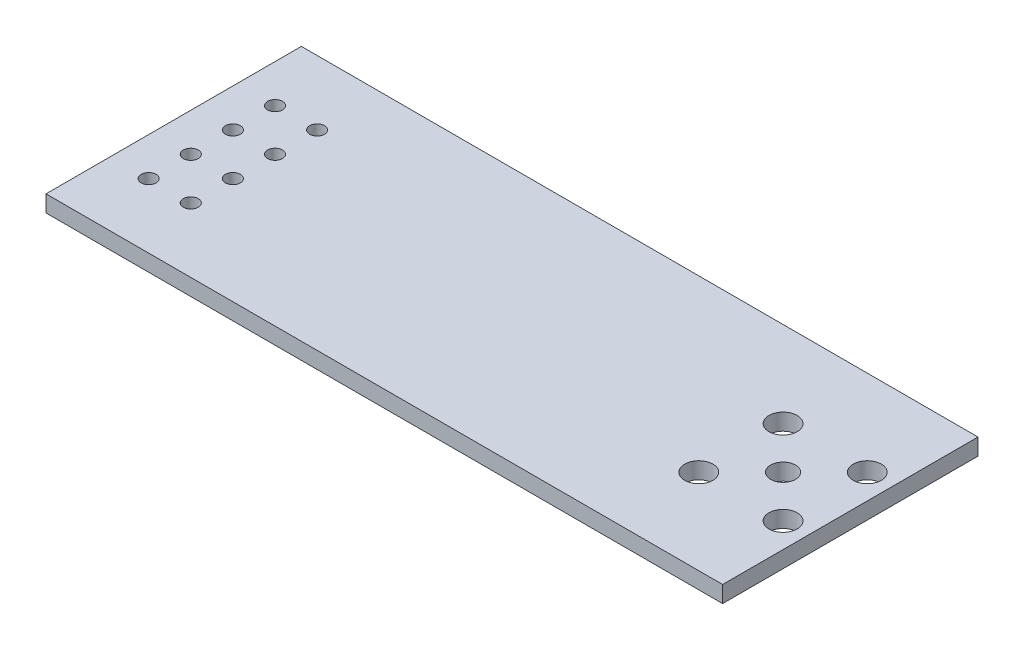
from build123d import *

# Parameters (mm, degrees)
SKETCH_1_W      = 40.8
SKETCH_1_H      = 15.4
SKETCH_1_R      = 0.45
SKETCH_1_R_2    = 0.85
SKETCH_1_R_3    = 0.75
EXTRUDE_1_DEPTH = 1


with BuildPart() as part:
    # Эскиз1 → Бобышка-Вытянуть1 (new body)
    with BuildSketch(Plane(origin=(0, 0, 0), x_dir=(1, 0, 0), z_dir=(0, 1, 0))):
        with Locations((20.4, 7.7)):
            Rectangle(SKETCH_1_W, SKETCH_1_H)
        with Locations((2.299992341, 3.89)):
            Circle(SKETCH_1_R, mode=Mode.SUBTRACT)
        with Locations((2.299993928, 6.43)):
            Circle(SKETCH_1_R, mode=Mode.SUBTRACT)
        with Locations((2.299995515, 8.97)):
            Circle(SKETCH_1_R, mode=Mode.SUBTRACT)
        with Locations((2.3, 11.51)):
            Circle(SKETCH_1_R, mode=Mode.SUBTRACT)
        with Locations((4.839992341, 3.89)):
            Circle(SKETCH_1_R, mode=Mode.SUBTRACT)
        with Locations((4.839992341, 6.43)):
            Circle(SKETCH_1_R, mode=Mode.SUBTRACT)
        with Locations((4.839992341, 8.97)):
            Circle(SKETCH_1_R, mode=Mode.SUBTRACT)
        with Locations((4.839992341, 11.51)):
            Circle(SKETCH_1_R, mode=Mode.SUBTRACT)
        with Locations((34.22, 5.144366898)):
            Circle(SKETCH_1_R_2, mode=Mode.SUBTRACT)
        with Locations((34.22, 10.224366898)):
            Circle(SKETCH_1_R_2, mode=Mode.SUBTRACT)
        with Locations((39.3, 5.144366898)):
            Circle(SKETCH_1_R_2, mode=Mode.SUBTRACT)
        with Locations((39.3, 10.224366898)):
            Circle(SKETCH_1_R_2, mode=Mode.SUBTRACT)
        with Locations((36.76, 7.684366898)):
            Circle(SKETCH_1_R_3, mode=Mode.SUBTRACT)
    extrude(amount=EXTRUDE_1_DEPTH)


solid = part.part
